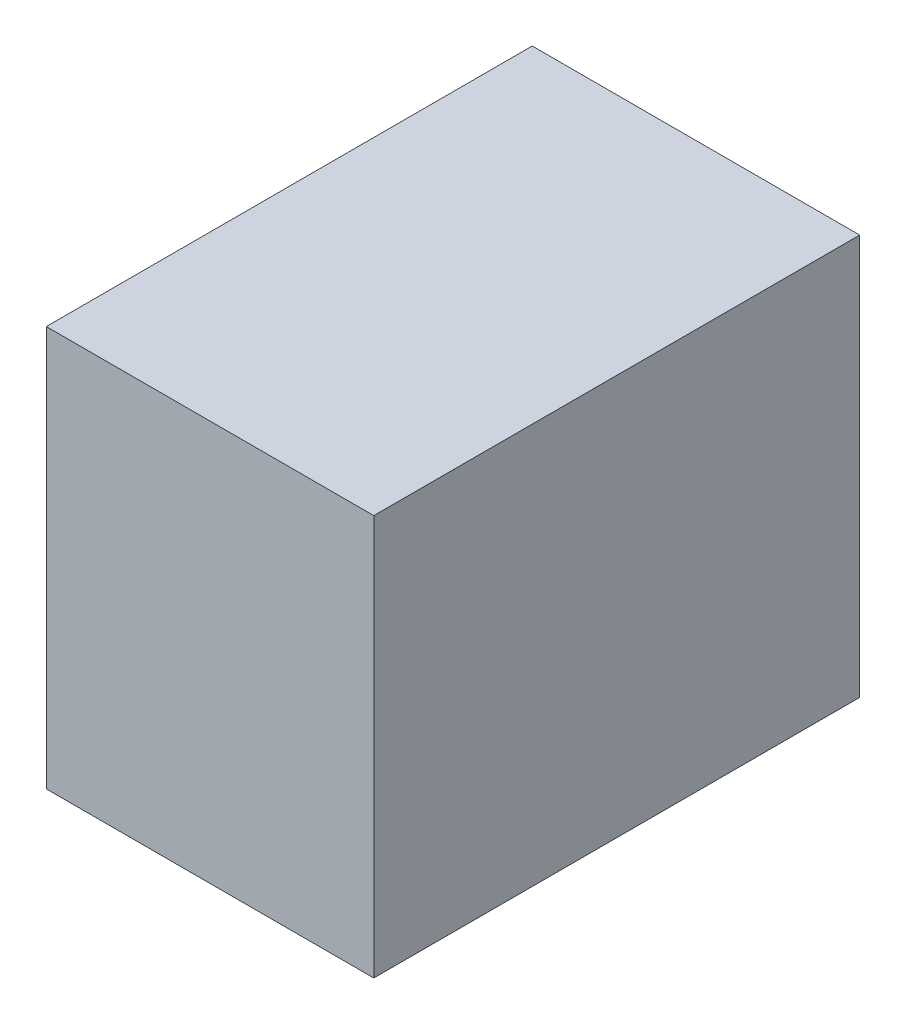
from build123d import *

# Parameters (mm, degrees)
SKETCH1_W           = 889
SKETCH1_H           = 1319.2125
BOSS_EXTRUDE1_DEPTH = 1087.12


with BuildPart() as part:
    # Sketch1 → Boss-Extrude1 (new body)
    with BuildSketch(Plane(origin=(0, 0, 0), x_dir=(1, 0, 0), z_dir=(0, 1, 0))):
        Rectangle(SKETCH1_W, SKETCH1_H)
    extrude(amount=BOSS_EXTRUDE1_DEPTH)


solid = part.part
